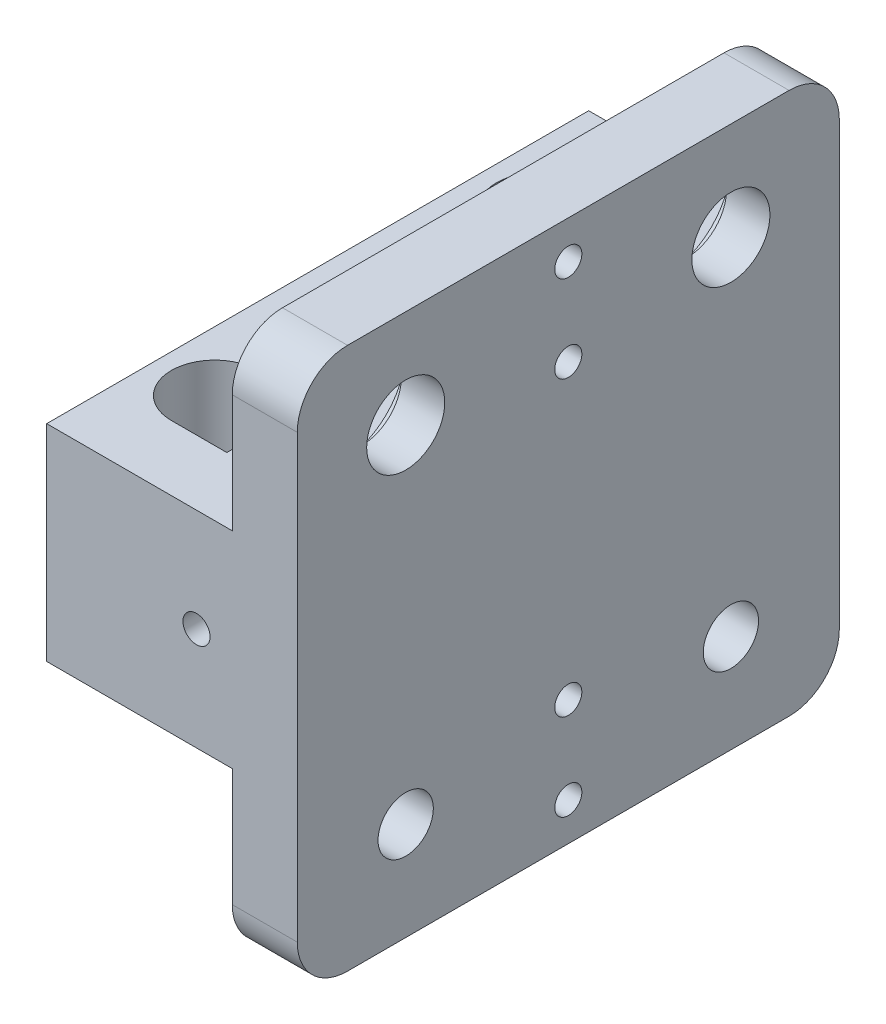
from build123d import *

# Parameters (mm, degrees)
SKETCH2_W                  = 50
SKETCH2_H                  = 50
BOSS_EXTRUDE1_DEPTH        = 6
SKETCH3_W                  = 50
SKETCH3_H                  = 19.118802154
BOSS_EXTRUDE2_DEPTH        = 9.5
BOSS_EXTRUDE3_DEPTH        = 12
SKETCH6_R                  = 3.6
SKETCH6_R_2                = 2.55
CUT_EXTRUDE2_DEPTH         = 41.193638748
SKETCH7_R                  = 5.05
SKETCH7_R_2                = 6
CUT_EXTRUDE3_DEPTH         = 2
M4X0_7_TAPPED_HOLE1_REACH  = 45.37
M4X0_7_TAPPED_HOLE1_BORE_R = 1.65
M4X0_7_TAPPED_HOLE2_D      = 3.3
M4X0_7_TAPPED_HOLE2_DEPTH  = 10
M4X0_7_TAPPED_HOLE2_TIP    = 0.991420021
FILLET1_R                  = 4.635
M3X0_5_TAPPED_HOLE1_D      = 2.5
M4X0_7_TAPPED_HOLE3_D      = 3.3
M4X0_7_TAPPED_HOLE3_DEPTH  = 6
M4X0_7_TAPPED_HOLE3_TIP    = 0.991420021
SKETCH17_R                 = 1.25
CUT_EXTRUDE4_DEPTH         = 60.080695659
SKETCH18_OUTSIDE_W         = 67.008
SKETCH18_OUTSIDE_H         = 67.008
SKETCH18_OUTSIDE_R         = 3
CUT_EXTRUDE5_DEPTH         = 2


with BuildPart() as part:
    # Sketch2 → Boss-Extrude1 (new body)
    with BuildSketch(Plane(origin=(0, 0, 0), x_dir=(0, 0, -1), z_dir=(1, 0, 0))):
        Rectangle(SKETCH2_W, SKETCH2_H)
    extrude(amount=BOSS_EXTRUDE1_DEPTH)

    # Sketch3 → Boss-Extrude2 (add, symmetric)
    with BuildSketch(Plane(origin=(25, 0, 0), x_dir=(0, 0, 1), z_dir=(0, 1, 0))):
        with Locations((0, -34.559401077)):
            Rectangle(SKETCH3_W, SKETCH3_H)
        with BuildLine():
            Line((-19, -32.42820323), (-19, -36.618802154))
            ThreePointArc((-19, -36.618802154), (-15, -40.618802154), (-11, -36.618802154))
            Line((-11, -36.618802154), (-11, -32.42820323))
            Line((-11, -32.42820323), (-11, -27.809401077))
            Line((-11, -27.809401077), (-15, -25.5))
            Line((-15, -25.5), (-19, -27.809401077))
            Line((-19, -27.809401077), (-19, -32.42820323))
        make_face(mode=Mode.SUBTRACT)
        with BuildLine():
            Line((11, -36.618802154), (11, -32.42820323))
            Line((11, -32.42820323), (11, -27.809401077))
            Line((11, -27.809401077), (15, -25.5))
            Line((15, -25.5), (19, -27.809401077))
            Line((19, -27.809401077), (19, -32.42820323))
            Line((19, -32.42820323), (19, -36.618802154))
            ThreePointArc((19, -36.618802154), (15, -40.618802154), (11, -36.618802154))
        make_face(mode=Mode.SUBTRACT)
    extrude(amount=BOSS_EXTRUDE2_DEPTH, both=True)

    # Sketch5 → Boss-Extrude3 (add)
    with BuildSketch(Plane(origin=(9.5, 9.5, 0), x_dir=(0, 0, 1), z_dir=(0, -1, 0))):
        Polygon((-19, 16), (-11, 16), (-11, 12.309401077), (-15, 10), (-19, 12.309401077), align=None)
        Polygon((11, 16), (19, 16), (19, 12.309401077), (15, 10), (11, 12.309401077), align=None)
    extrude(amount=BOSS_EXTRUDE3_DEPTH)

    # Sketch6 → Cut-Extrude2 (cut, through all)
    with BuildSketch(Plane(origin=(0, 0, 0), x_dir=(0, 0, -1), z_dir=(1, 0, 0))):
        with Locations((-15, 15.95)):
            Circle(SKETCH6_R)
        with Locations((15, 15.95)):
            Circle(SKETCH6_R)
        with Locations((-15, -15.95)):
            Circle(SKETCH6_R_2)
        with Locations((15, -15.95)):
            Circle(SKETCH6_R_2)
    extrude(amount=CUT_EXTRUDE2_DEPTH, mode=Mode.SUBTRACT)

    # Sketch7 → Cut-Extrude3 (cut)
    with BuildSketch(Plane.ZY):
        with Locations((-15, -15.95)):
            Circle(SKETCH7_R)
        with Locations((15, -15.95)):
            Circle(SKETCH7_R)
        with Locations((-15, 15.95)):
            Circle(SKETCH7_R_2)
        with Locations((15, 15.95)):
            Circle(SKETCH7_R_2)
    extrude(amount=-CUT_EXTRUDE3_DEPTH, mode=Mode.SUBTRACT)

    # M4x0.7 Tapped Hole1 bore → M4x0.7 Tapped Hole1 (cut, up to next)
    with BuildSketch(Plane(origin=(-19.118802154, 0, 0), x_dir=(0, -1, 0), z_dir=(-1, 0, 0)), mode=Mode.PRIVATE) as m4x0_7_tapped_hole1_sk1:
        with Locations((5.5, -15)):
            Circle(M4X0_7_TAPPED_HOLE1_BORE_R)
    m4x0_7_tapped_hole1_tool1 = extrude(m4x0_7_tapped_hole1_sk1.sketch, amount=-M4X0_7_TAPPED_HOLE1_REACH, mode=Mode.PRIVATE) & part.part
    # M4x0.7 Tapped Hole1 bore → M4x0.7 Tapped Hole1 (cut, up to next)
    with BuildSketch(Plane(origin=(-19.118802154, 0, 0), x_dir=(0, -1, 0), z_dir=(-1, 0, 0)), mode=Mode.PRIVATE) as m4x0_7_tapped_hole1_sk2:
        with Locations((5.5, 15)):
            Circle(M4X0_7_TAPPED_HOLE1_BORE_R)
    m4x0_7_tapped_hole1_tool2 = extrude(m4x0_7_tapped_hole1_sk2.sketch, amount=-M4X0_7_TAPPED_HOLE1_REACH, mode=Mode.PRIVATE) & part.part
    add(m4x0_7_tapped_hole1_tool1.solids().sort_by_distance((-19.118802, -5.5, -15))[0], mode=Mode.SUBTRACT)
    add(m4x0_7_tapped_hole1_tool2.solids().sort_by_distance((-19.118802, -5.5, 15))[0], mode=Mode.SUBTRACT)

    # M4x0.7 Tapped Hole2
    with Locations(Plane.ZY.offset(19.118802154)):
        with Locations((-9.525, 1.96821034), (9.525, 1.96821034)):
            Hole(M4X0_7_TAPPED_HOLE2_D / 2, depth=M4X0_7_TAPPED_HOLE2_DEPTH)
            with Locations((0, 0, -(M4X0_7_TAPPED_HOLE2_DEPTH + M4X0_7_TAPPED_HOLE2_TIP / 2))):  # 118° drill point
                Cone(0, M4X0_7_TAPPED_HOLE2_D / 2, M4X0_7_TAPPED_HOLE2_TIP, mode=Mode.SUBTRACT)

    # Fillet1
    fillet1_edges = [part.edges().sort_by_distance(p)[0] for p in [
        (3, -25, -25),
        (3, -25, 25),
        (3, 25, 25),
        (3, 25, -25),
    ]]
    fillet(fillet1_edges, radius=FILLET1_R)

    # M3x0.5 Tapped Hole1 (through all)
    with Locations(Plane.ZY):
        with Locations((0, 21.5), (0, -21.5), (0, -13.5), (0, 13.5)):
            Hole(M3X0_5_TAPPED_HOLE1_D / 2)

    # M4x0.7 Tapped Hole3
    with Locations(Plane(origin=(0, 9.5, 0), x_dir=(1, 0, 0), z_dir=(0, 1, 0))):
        with Locations((-4.95, 0)):
            Hole(M4X0_7_TAPPED_HOLE3_D / 2, depth=M4X0_7_TAPPED_HOLE3_DEPTH)
            with Locations((0, 0, -(M4X0_7_TAPPED_HOLE3_DEPTH + M4X0_7_TAPPED_HOLE3_TIP / 2))):  # 118° drill point
                Cone(0, M4X0_7_TAPPED_HOLE3_D / 2, M4X0_7_TAPPED_HOLE3_TIP, mode=Mode.SUBTRACT)

    # Sketch17 → Cut-Extrude4 (cut, through all)
    with BuildSketch(Plane(origin=(0, 0, -25), x_dir=(-1, 0, 0), z_dir=(0, 0, -1))):
        with Locations((3.3, 0)):
            Circle(SKETCH17_R)
    extrude(amount=-CUT_EXTRUDE4_DEPTH, mode=Mode.SUBTRACT)

    # Sketch18 outside → Cut-Extrude5 (cut)
    with BuildSketch(Plane.ZY.offset(19.118802154)):
        Rectangle(SKETCH18_OUTSIDE_W, SKETCH18_OUTSIDE_H)
        with Locations((-9.525, 1.96821034)):
            Circle(SKETCH18_OUTSIDE_R, mode=Mode.SUBTRACT)
        with Locations((9.525, 1.96821034)):
            Circle(SKETCH18_OUTSIDE_R, mode=Mode.SUBTRACT)
    extrude(amount=-CUT_EXTRUDE5_DEPTH, mode=Mode.SUBTRACT)


solid = part.part
